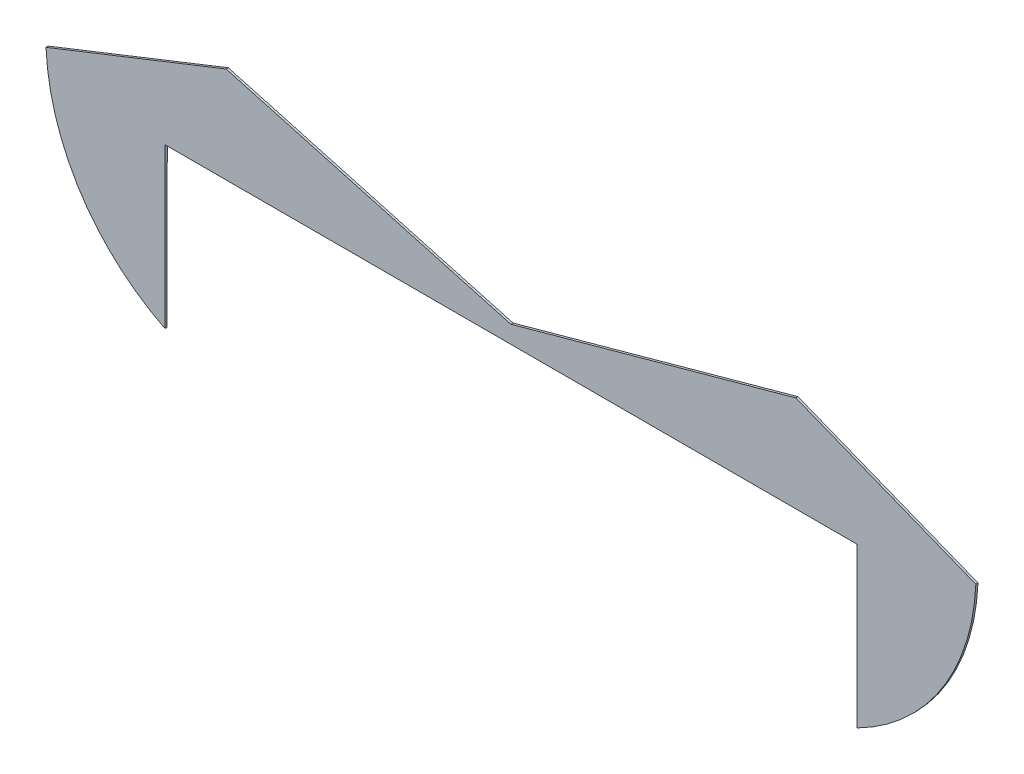
from build123d import *

# Parameters (mm, degrees)
SALIENTE_EXTRUIR1_DEPTH = 0.1


with BuildPart() as part:
    # Model → Saliente-Extruir1 (new body)
    with BuildSketch(Plane.XY):
        with BuildLine():
            Line((18.549433899, 16.929238501), (35.049433899, 16.929238501))
            Line((35.049433899, 16.929238501), (50.549433899, 16.929238501))
            Line((50.549433899, 16.929238501), (50.549433899, 9.564394878))
            ThreePointArc((50.549433899, 9.564394878), (52.846061309, 11.155038033), (54.613628105, 13.318449858))
            ThreePointArc((54.613628105, 13.318449858), (55.63441871, 15.607287158), (56.05464892, 18.077954318))
            Line((56.05464892, 18.077954318), (47.725070346, 21.375387298))
            Line((47.725070346, 21.375387298), (34.549148093, 17.736158759))
            Line((34.549148093, 17.736158759), (21.373432242, 21.375830254))
            Line((21.373432242, 21.375830254), (13.040093285, 18.077232707))
            ThreePointArc((13.040093285, 18.077232707), (13.464781987, 15.585792102), (14.494191445, 13.277556205))
            ThreePointArc((14.494191445, 13.277556205), (16.258659897, 11.134658879), (18.546640013, 9.562874906))
            Line((18.546640013, 9.562874906), (18.549433899, 16.929238501))
        make_face()
    extrude(amount=SALIENTE_EXTRUIR1_DEPTH)


solid = part.part
